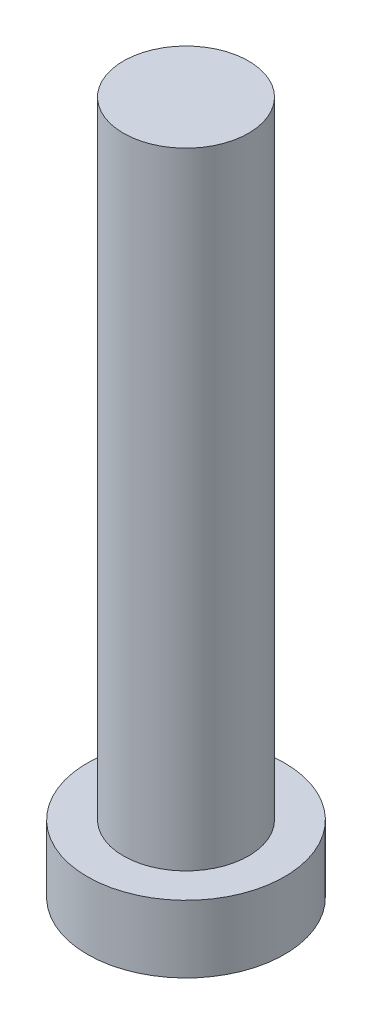
from build123d import *

# Parameters (mm, degrees)
SKETCH_1_R          = 3.15
EXTRUDE_1_DEPTH     = 2.15
SKETCH_2_R          = 2
EXTRUDE_2_DEPTH     = 20
CUT_EXTRUDE_1_DEPTH = 1.5


with BuildPart() as part:
    # 草图1 → 凸台-拉伸1 (new body)
    with BuildSketch(Plane(origin=(0, 0, 0), x_dir=(1, 0, 0), z_dir=(0, 1, 0))):
        Circle(SKETCH_1_R)
    extrude(amount=EXTRUDE_1_DEPTH)

    # 草图2 → 凸台-拉伸2 (add)
    with BuildSketch(Plane(origin=(0, 2.15, 0), x_dir=(1, 0, 0), z_dir=(0, 1, 0))):
        Circle(SKETCH_2_R)
    extrude(amount=EXTRUDE_2_DEPTH)

    # 草图3 → 切除-拉伸1 (cut)
    with BuildSketch(Plane.XZ):
        with BuildLine():
            Line((-0.5, 1), (-0.5, 2))
            Line((-0.5, 2), (0.5, 2))
            Line((0.5, 2), (0.5, 1))
            ThreePointArc((0.5, 1), (0.646446609, 0.646446609), (1, 0.5))
            Line((1, 0.5), (2, 0.5))
            Line((2, 0.5), (2, -0.5))
            Line((2, -0.5), (1, -0.5))
            ThreePointArc((1, -0.5), (0.646446609, -0.646446609), (0.5, -1))
            Line((0.5, -1), (0.5, -2))
            Line((0.5, -2), (-0.5, -2))
            Line((-0.5, -2), (-0.5, -1))
            ThreePointArc((-0.5, -1), (-0.646446609, -0.646446609), (-1, -0.5))
            Line((-1, -0.5), (-2, -0.5))
            Line((-2, -0.5), (-2, 0.5))
            Line((-2, 0.5), (-1, 0.5))
            ThreePointArc((-1, 0.5), (-0.646446609, 0.646446609), (-0.5, 1))
        make_face()
    extrude(amount=-CUT_EXTRUDE_1_DEPTH, mode=Mode.SUBTRACT)


solid = part.part
